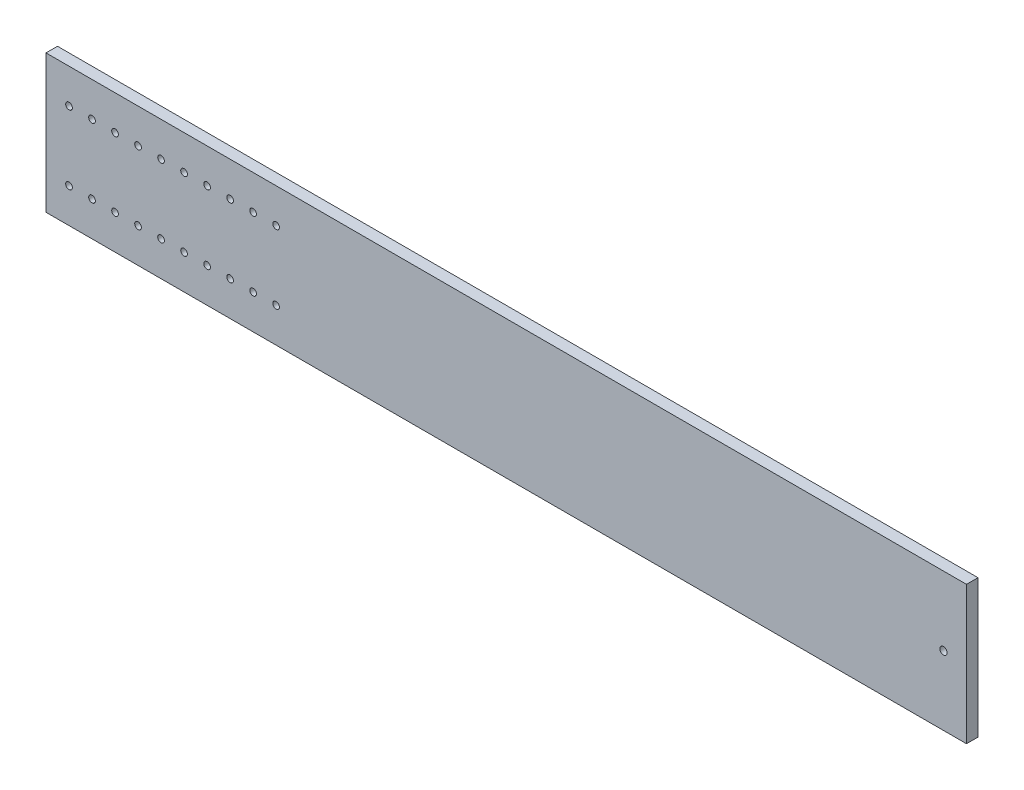
from build123d import *

# Parameters (mm, degrees)
SKETCH1_W             = 508
SKETCH1_H             = 76.2
BASIC_PLANK_DEPTH     = 6.35
SKETCH2_R             = 1.8415
PLACEMENT_HOLES_DEPTH = 7.35
SKETCH3_R             = 2.0066
WHEEL_HOLE_DEPTH      = 7.35


with BuildPart() as part:
    # Sketch1 → basic_plank (new body)
    with BuildSketch(Plane.XY):
        with Locations((254, 38.1)):
            Rectangle(SKETCH1_W, SKETCH1_H)
    extrude(amount=BASIC_PLANK_DEPTH)

    # Sketch2 → placement holes (cut, through all)
    with BuildSketch(Plane.XY.offset(6.35)):
        with Locations((12.7, 57.15)):
            Circle(SKETCH2_R)
        with Locations((25.4, 57.15)):
            Circle(SKETCH2_R)
        with Locations((38.1, 57.15)):
            Circle(SKETCH2_R)
        with Locations((50.8, 57.15)):
            Circle(SKETCH2_R)
        with Locations((63.5, 57.15)):
            Circle(SKETCH2_R)
        with Locations((76.2, 57.15)):
            Circle(SKETCH2_R)
        with Locations((88.9, 57.15)):
            Circle(SKETCH2_R)
        with Locations((101.6, 57.15)):
            Circle(SKETCH2_R)
        with Locations((114.3, 57.15)):
            Circle(SKETCH2_R)
        with Locations((127, 57.15)):
            Circle(SKETCH2_R)
        with Locations((12.7, 19.05)):
            Circle(SKETCH2_R)
        with Locations((25.4, 19.05)):
            Circle(SKETCH2_R)
        with Locations((38.1, 19.05)):
            Circle(SKETCH2_R)
        with Locations((50.8, 19.05)):
            Circle(SKETCH2_R)
        with Locations((63.5, 19.05)):
            Circle(SKETCH2_R)
        with Locations((76.2, 19.05)):
            Circle(SKETCH2_R)
        with Locations((88.9, 19.05)):
            Circle(SKETCH2_R)
        with Locations((101.6, 19.05)):
            Circle(SKETCH2_R)
        with Locations((114.3, 19.05)):
            Circle(SKETCH2_R)
        with Locations((127, 19.05)):
            Circle(SKETCH2_R)
    extrude(amount=-PLACEMENT_HOLES_DEPTH, mode=Mode.SUBTRACT)

    # Sketch3 → wheel_hole (cut, through all)
    with BuildSketch(Plane.XY.offset(6.35)):
        with Locations((495.3, 38.1)):
            Circle(SKETCH3_R)
    extrude(amount=-WHEEL_HOLE_DEPTH, mode=Mode.SUBTRACT)


solid = part.part
